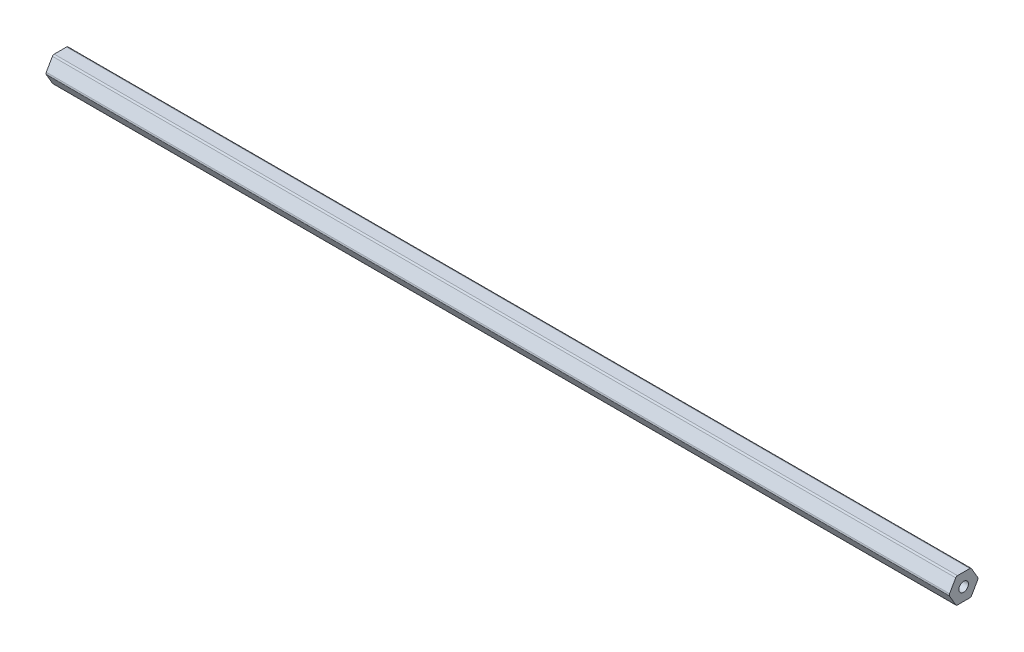
from build123d import *

# Parameters (mm, degrees)
SKETCH1_R                = 2.38125
BOSS_EXTRUDE1_DEPTH      = 225.425
BOSS_EXTRUDE1_DEPTH_BACK = 225.425


with BuildPart() as part:
    # Sketch1 → Boss-Extrude1 (new body, two sides)
    with BuildSketch(Plane(origin=(0, 0, 0), x_dir=(0, 0, -1), z_dir=(1, 0, 0))) as boss_extrude1_sk:
        with BuildLine():
            Line((7.039054482, 0.508), (3.959468146, 5.842))
            ThreePointArc((3.959468146, 5.842), (3.587586336, 6.21388181), (3.079586336, 6.35))
            Line((3.079586336, 6.35), (-3.079586336, 6.35))
            ThreePointArc((-3.079586336, 6.35), (-3.587586336, 6.21388181), (-3.959468146, 5.842))
            Line((-3.959468146, 5.842), (-7.039054482, 0.508))
            ThreePointArc((-7.039054482, 0.508), (-7.175172672, 0), (-7.039054482, -0.508))
            Line((-7.039054482, -0.508), (-3.959468146, -5.842))
            ThreePointArc((-3.959468146, -5.842), (-3.587586336, -6.21388181), (-3.079586336, -6.35))
            Line((-3.079586336, -6.35), (3.079586336, -6.35))
            ThreePointArc((3.079586336, -6.35), (3.587586336, -6.21388181), (3.959468146, -5.842))
            Line((3.959468146, -5.842), (7.039054482, -0.508))
            ThreePointArc((7.039054482, -0.508), (7.175172672, 0), (7.039054482, 0.508))
        make_face()
        Circle(SKETCH1_R, mode=Mode.SUBTRACT)
    extrude(amount=BOSS_EXTRUDE1_DEPTH)
    extrude(boss_extrude1_sk.sketch, amount=-BOSS_EXTRUDE1_DEPTH_BACK)


solid = part.part
